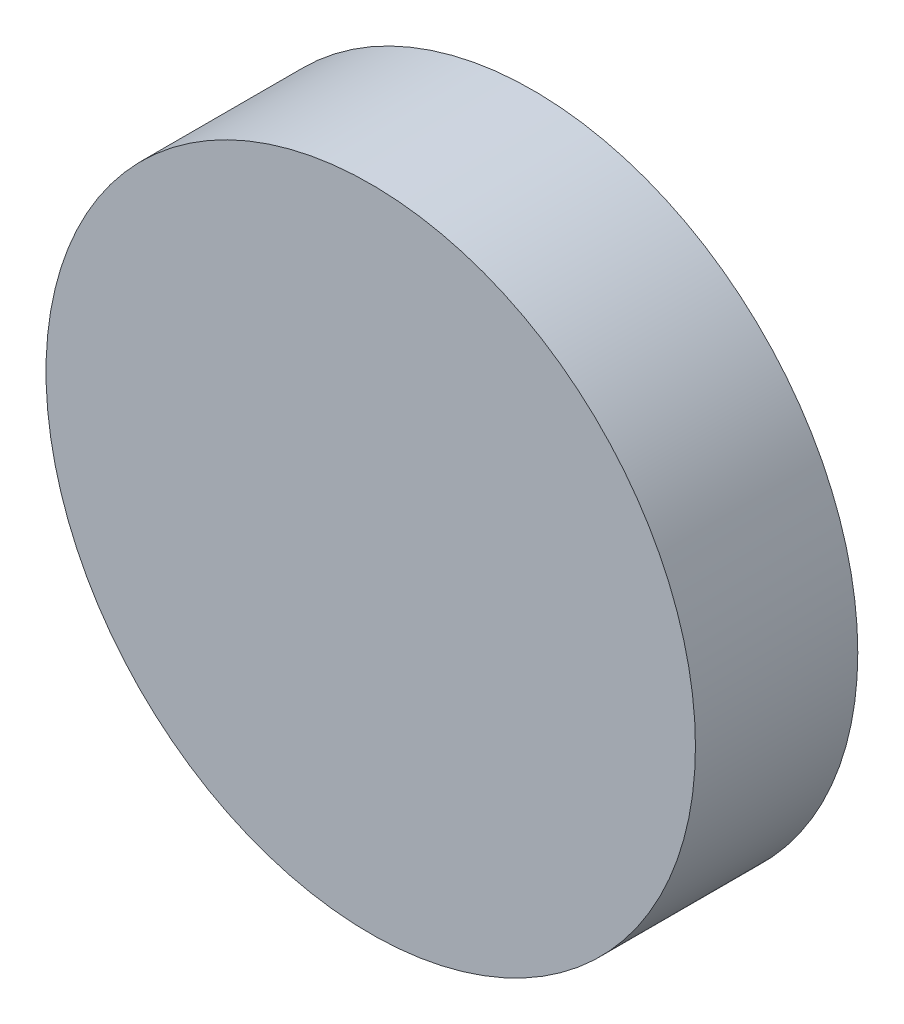
from build123d import *

# Parameters (mm, degrees)
SKETCH1_R           = 10
BOSS_EXTRUDE1_DEPTH = 5


with BuildPart() as part:
    # Sketch1 → Boss-Extrude1 (new body)
    with BuildSketch(Plane.XY):
        Circle(SKETCH1_R)
    extrude(amount=BOSS_EXTRUDE1_DEPTH)


solid = part.part
